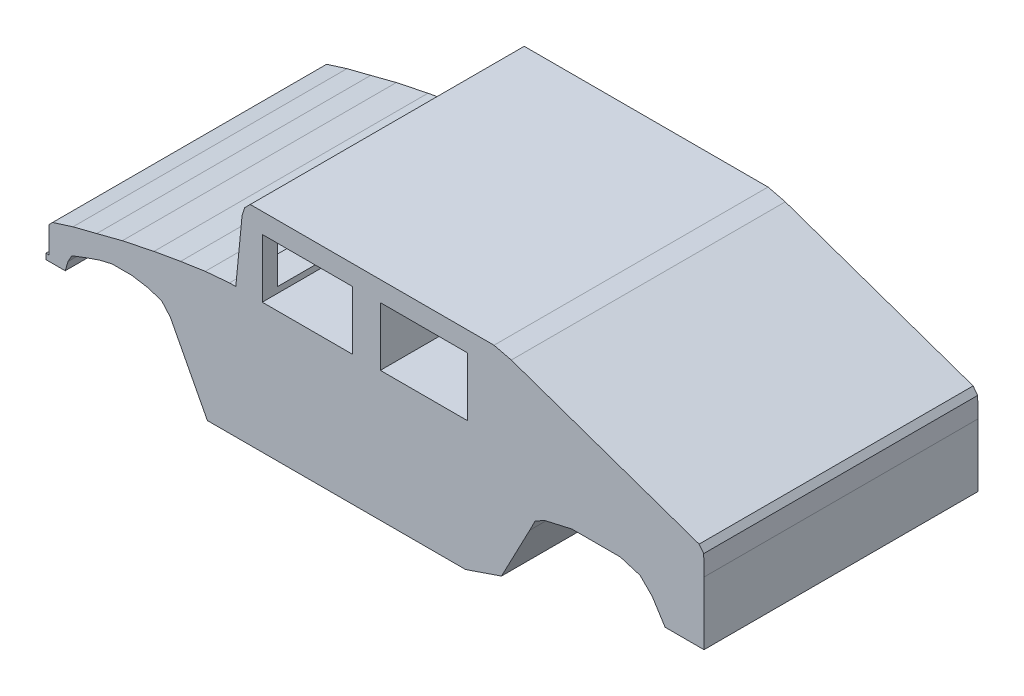
from build123d import *

# Parameters (mm, degrees)
EXTRUDE1_DEPTH     = 150
SKETCH2_W          = 49.298496038
SKETCH2_H          = 32.135315936
SKETCH2_W_2        = 47.837799858
CUT_EXTRUDE1_DEPTH = 150
SKETCH3_W          = 134.99868738
SKETCH3_H          = 27.09229113
CUT_EXTRUDE2_DEPTH = 20


with BuildPart() as part:
    # Sketch1 → Extrude1 (new body)
    with BuildSketch(Plane.XY):
        Polygon((-118.530936898, -6.633049378), (-123.315790789, -1.210214968), (-131.077887101, 1.235377021), (-139.690624105, 2.617668145), (-150.429962839, 2.617668145), (-157.235088373, 1.022716848), (-164.571864339, -1.529205227), (-172.440290738, -4.506447648), (-174.566892467, -8.334330761), (-176.055513678, -13.438174912), (-186.582192239, -13.438174912), (-186.582192239, -10.354602404), (-184.880910855, -10.354602404), (-184.880910855, 4.106289356), (-182.966969299, 6.020230912), (-171.802310219, 9.529123766), (-158.83003967, 12.825356447), (-144.794468256, 16.440579387), (-127.462664161, 20.055802326), (-112.895442315, 22.607724402), (-99.391521333, 24.627996045), (-86.121526623, 25.776360974), (-82.676431684, 25.776360974), (-79.231336746, 61.248079229), (-77.827779548, 65.58634693), (-74.765472936, 68.648653542), (58.700056904, 68.648653542), (68.142168958, 66.351923583), (170.984632679, 30.497417), (173.488753661, 27.243716225), (173.664150964, 16.206652811), (173.664150964, -18.244296574), (152.355600789, -18.244296574), (145.337814803, -7.143435106), (138.702817143, -0.508437446), (127.857147893, 2.809061383), (115.480325336, 2.809061383), (101.317157255, 2.809061383), (86.771200848, -0.508437446), (81.284568168, -3.315551841), (78.222261556, -9.312568956), (62.783132387, -38.787270097), (43.133331627, -45.489442613), (-81.740726979, -45.549861026), (-98.221890382, -45.549861026), align=None)
    extrude(amount=EXTRUDE1_DEPTH)

    # Sketch2 → Cut-Extrude1 (cut)
    with BuildSketch(Plane.XY.offset(150)):
        with Locations((-43.524186177, 41.676254948)):
            Rectangle(SKETCH2_W, SKETCH2_H)
        with Locations((20.38127165, 41.676254948)):
            Rectangle(SKETCH2_W_2, SKETCH2_H)
    extrude(amount=-CUT_EXTRUDE1_DEPTH, mode=Mode.SUBTRACT)

    # Sketch3 → Cut-Extrude2 (cut)
    with BuildSketch(Plane(origin=(-84.383919497, 8.195560527, 0), x_dir=(0, 0, 1), z_dir=(-0.995316735, 0.096667453, 0))):
        with Locations((74.261219998, 35.654596801)):
            Rectangle(SKETCH3_W, SKETCH3_H)
    extrude(amount=-CUT_EXTRUDE2_DEPTH, mode=Mode.SUBTRACT)


solid = part.part
